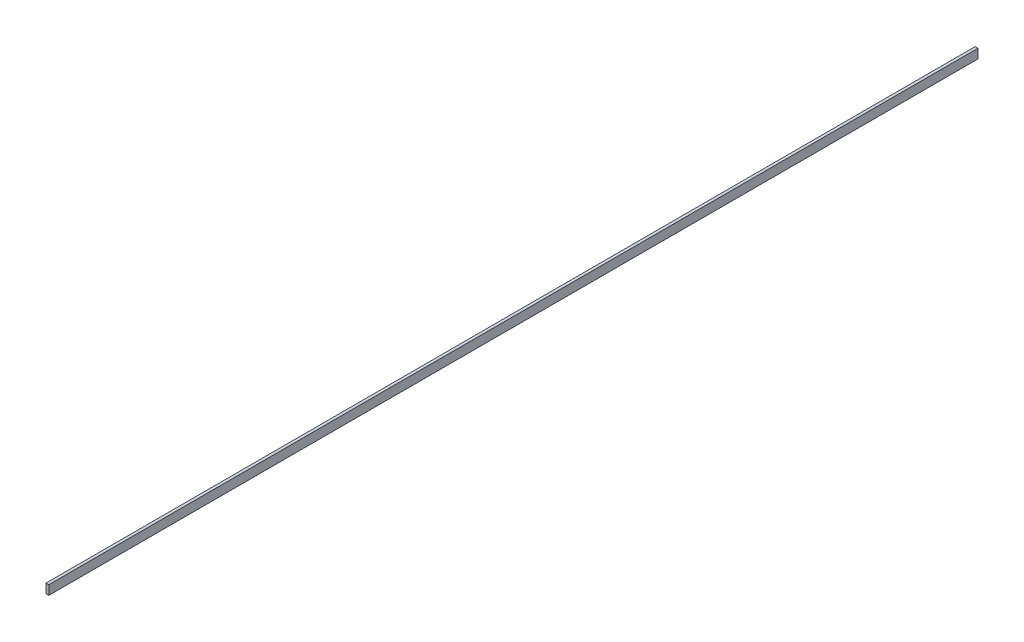
from build123d import *

# Parameters (mm, degrees)
SKETCH2_W           = 3
SKETCH2_H           = 10
BOSS_EXTRUDE1_DEPTH = 1000


with BuildPart() as part:
    # Sketch2 → Boss-Extrude1 (new body)
    with BuildSketch(Plane.XY):
        with Locations((1.5, -5)):
            Rectangle(SKETCH2_W, SKETCH2_H)
    extrude(amount=-BOSS_EXTRUDE1_DEPTH)


solid = part.part
